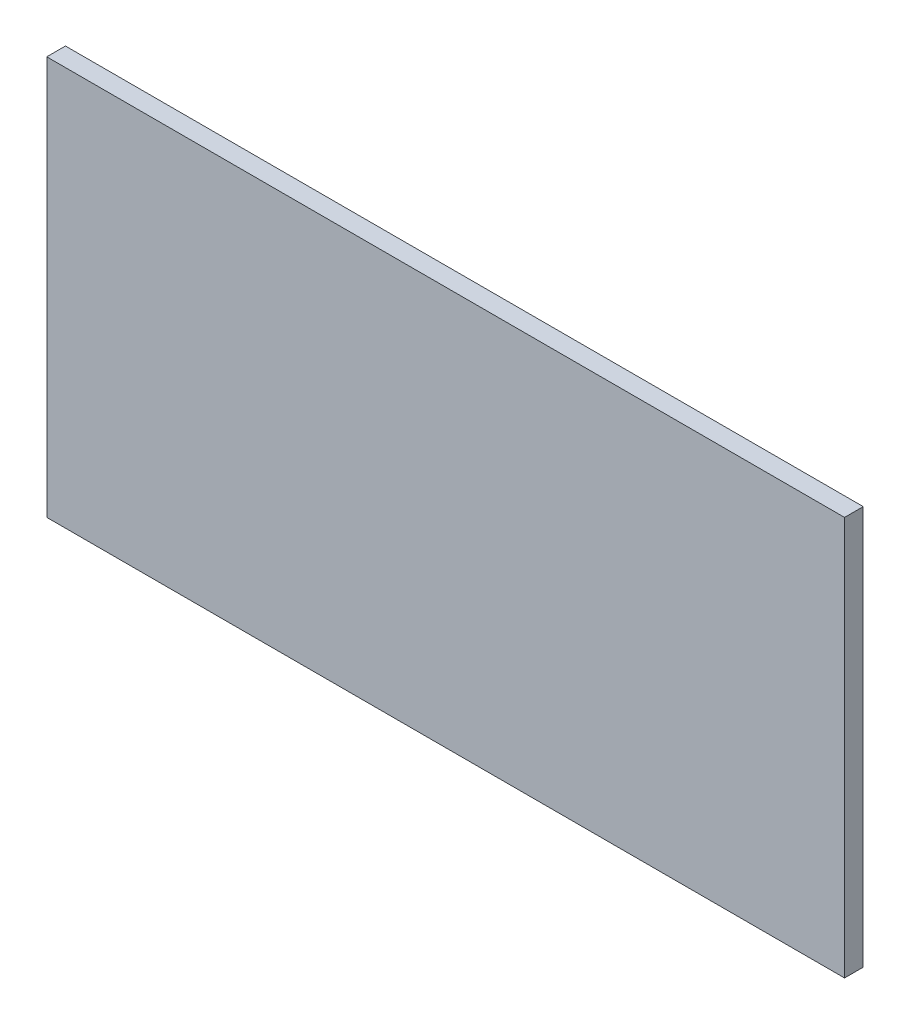
from build123d import *

# Parameters (mm, degrees)
SKETCH_1_W      = 128
SKETCH_1_H      = 64
EXTRUDE_1_DEPTH = 3


with BuildPart() as part:
    # 草图1 → 凸台-拉伸1 (new body)
    with BuildSketch(Plane.XY):
        Rectangle(SKETCH_1_W, SKETCH_1_H)
    extrude(amount=EXTRUDE_1_DEPTH)


solid = part.part
